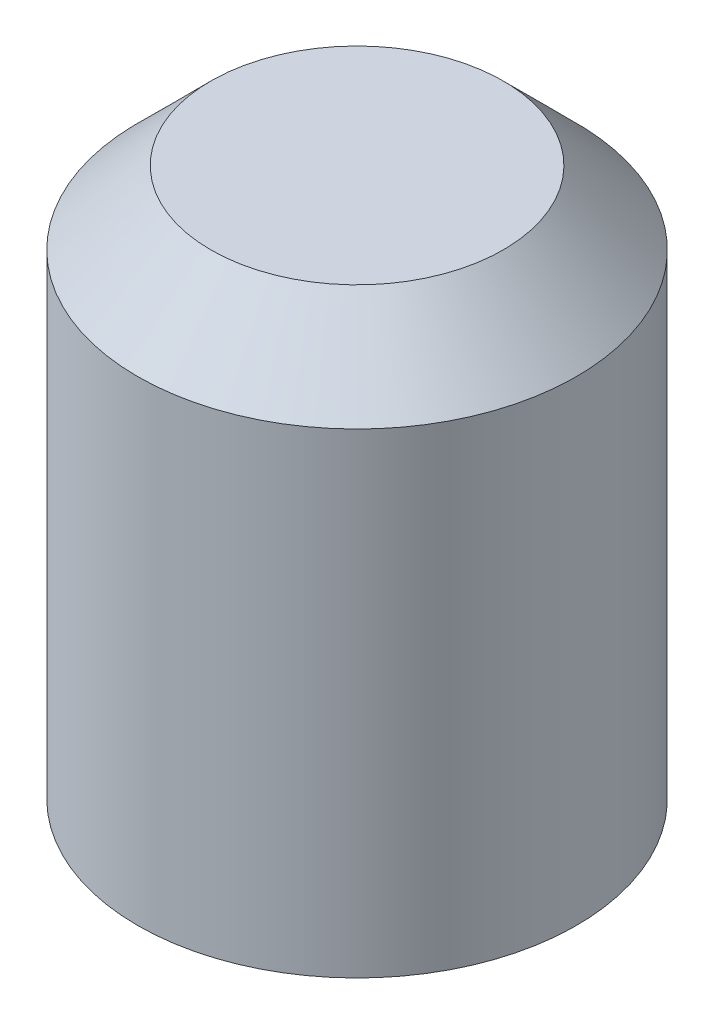
from build123d import *

# Parameters (mm, degrees)
SKETCH1_R           = 6
BOSS_EXTRUDE1_DEPTH = 15
CHAMFER1_SIZE       = 2


with BuildPart() as part:
    # Sketch1 → Boss-Extrude1 (new body)
    with BuildSketch(Plane(origin=(0, 0, 0), x_dir=(1, 0, 0), z_dir=(0, 1, 0))):
        with Locations(Location((0, 0, 0), (0, 0, 270))):  # turned: the seam where the file's is
            Circle(SKETCH1_R)
    extrude(amount=BOSS_EXTRUDE1_DEPTH)

    # Chamfer1
    chamfer1_edges = [part.edges().sort_by_distance(p)[0] for p in [
        (0, 15, -6),
    ]]
    chamfer(chamfer1_edges, length=CHAMFER1_SIZE)


solid = part.part
